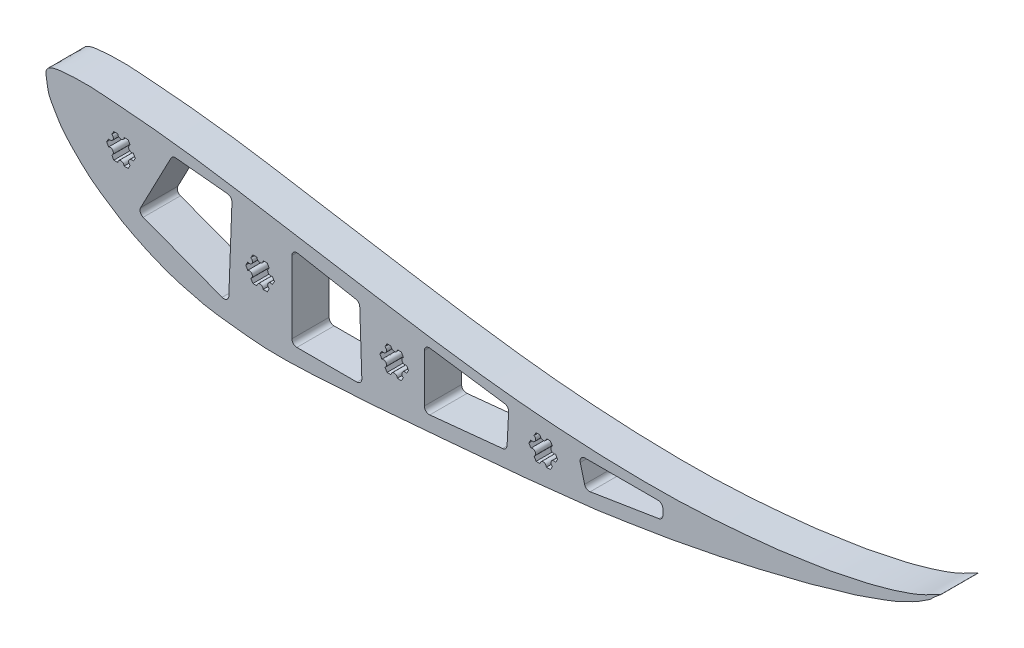
from build123d import *

# Parameters (mm, degrees)
BOSS_EXTRUDE1_DEPTH = 19.05
CUT_EXTRUDE3_DEPTH  = 381


with BuildPart() as part:
    # Sketch1 → Boss-Extrude1 (new body)
    with BuildSketch(Plane.XY):
        with BuildLine():
            add(Edge.make_bspline(
                [(-16.622525288, 91.56967272), (-16.794942994, 92.772317911), (-17.515788121, 97.582670832), (-2.852582554, 99.497127174), (9.154054709, 99.213304724), (23.433217875, 97.797752429), (34.6859051, 97.019819773), (46.592767258, 95.707761604), (58.472171701, 94.254609297), (72.666253463, 92.219697635), (88.15460255, 89.685431784), (109.15740223, 86.162485471), (130.076144789, 82.711728928), (150.055716296, 79.576696099), (168.256858053, 76.617688262), (186.559493812, 73.857794613), (206.695059336, 71.20791695), (225.195546149, 69.114961125), (244.068606399, 67.656695297), (262.594452449, 66.476567979), (282.222526995, 65.926744761), (300.99609332, 65.813021246), (318.737894065, 66.539084176), (334.742865336, 67.61277327), (348.252438633, 69.009944705), (359.067906447, 70.049570339), (367.896874578, 71.420704301), (377.007425502, 72.883057797), (386.227823421, 74.138373924), (395.367743176, 76.385575861), (403.564697097, 77.907582397), (410.735250399, 79.953005658), (417.114285798, 81.687412008), (422.732680223, 83.591992804), (427.164087313, 85.094079009), (431.171696898, 86.937153076), (434.607250511, 88.392786361), (443.123217376, 93.275688905), (437.255094337, 89.117703468), (435.279778464, 86.561175616), (431.573501891, 84.704524529), (428.464842726, 82.201032813), (424.134266462, 80.398696308), (419.425258521, 77.797857577), (414.105440345, 75.713007702), (408.77839072, 73.798734141), (403.684867312, 72.029145889), (396.961540144, 69.466067962), (387.343622202, 67.136732033), (376.830663922, 63.608926675), (365.24798357, 60.901656463), (354.754672426, 58.255886458), (344.650791699, 55.720154361), (336.670341174, 53.941801639), (329.235250959, 52.381752299), (321.327868225, 50.676833739), (310.892392252, 48.725728026), (298.426712372, 46.308387166), (284.136528131, 44.189578856), (268.909448728, 41.574011521), (251.075314715, 39.596728872), (229.386892765, 37.203012777), (203.753382466, 34.933554815), (177.46976253, 32.720447696), (150.443659112, 30.344574846), (123.02307167, 28.688327838), (101.004781565, 27.555963663), (84.804305156, 28.931500406), (75.72348416, 30.010523718), (67.270753352, 30.977463397), (60.250592801, 32.582425676), (53.932519662, 34.232006507), (47.114759922, 36.133551764), (41.43120503, 38.368275103), (36.428795002, 40.445297648), (32.069577899, 42.402430324), (27.662403595, 44.667790264), (23.104788958, 46.965799851), (18.73168781, 49.734821084), (12.723675127, 53.669846892), (5.809434759, 58.404883079), (-1.037305312, 65.077409289), (-6.513200759, 70.614178991), (-10.540658158, 76.008047875), (-12.880350205, 80.406543609), (-15.167480815, 84.128221175), (-16.123087236, 87.961419413), (-16.453570873, 90.391184614), (-16.622525288, 91.56967272)],
                knots=[0, 0, 0, 0, 0.003644297, 0.013581344, 0.034074787, 0.047557163, 0.057150579, 0.06958931, 0.084962672, 0.094623108, 0.114452008, 0.134073068, 0.161263036, 0.180794832, 0.197357561, 0.218965716, 0.238711125, 0.26090768, 0.277214827, 0.297940316, 0.318988728, 0.338651177, 0.356673355, 0.374539934, 0.388835783, 0.399172974, 0.408530924, 0.416784345, 0.428053881, 0.437617365, 0.446213781, 0.454125754, 0.460928052, 0.466918155, 0.472615005, 0.475771621, 0.480179638, 0.487250343, 0.490988881, 0.49507496, 0.498775568, 0.503369536, 0.507624299, 0.513322415, 0.520215853, 0.525455504, 0.531043662, 0.537088919, 0.5479516, 0.561953721, 0.571760074, 0.585151118, 0.595822817, 0.604354359, 0.61073386, 0.619595652, 0.629664863, 0.643953388, 0.659323518, 0.674864947, 0.692287919, 0.715453133, 0.743149301, 0.772805526, 0.797998576, 0.828023399, 0.858832685, 0.866768477, 0.87886578, 0.88746214, 0.893357873, 0.901377327, 0.907903322, 0.915486693, 0.920464298, 0.924856032, 0.930432876, 0.935970498, 0.940815755, 0.946613865, 0.958462559, 0.966932993, 0.97647901, 0.982815006, 0.98789669, 0.992067686, 0.996428904, 1, 1, 1, 1], degree=3))
        make_face()
    extrude(amount=BOSS_EXTRUDE1_DEPTH)

    # Sketch4 → Cut-Extrude3 (cut)
    with BuildSketch(Plane.XY.offset(19.05)):
        with BuildLine():
            Line((88.931300118, 66.243537573), (91.009974327, 66.243537573))
            ThreePointArc((91.009974327, 66.243537573), (92.597474327, 64.656037573), (94.184974327, 66.243537573))
            Line((94.184974327, 66.243537573), (96.263648536, 66.243537573))
            Line((96.263648536, 66.243537573), (97.302985641, 64.443352902))
            ThreePointArc((97.302985641, 64.443352902), (96.721920503, 62.274787243), (98.890486301, 61.693722626))
            Line((98.890486301, 61.693722626), (99.929823515, 59.893537766))
            Line((99.929823515, 59.893537766), (98.89048641, 58.093353094))
            ThreePointArc((98.89048641, 58.093353094), (96.721921082, 57.512287766), (97.30298641, 55.343722437))
            Line((97.30298641, 55.343722437), (96.263649306, 53.543537766))
            Line((96.263649306, 53.543537766), (94.184975096, 53.543537766))
            ThreePointArc((94.184975096, 53.543537766), (92.597475, 55.131037573), (91.009975096, 53.543537573))
            Line((91.009975096, 53.543537573), (88.931300887, 53.543537573))
            Line((88.931300887, 53.543537573), (87.891963673, 55.343722182))
            ThreePointArc((87.891963673, 55.343722182), (88.47302887, 57.512287545), (86.304463507, 58.093352743))
            Line((86.304463507, 58.093352743), (85.265126293, 59.893537351))
            Line((85.265126293, 59.893537351), (86.304463288, 61.693722086))
            ThreePointArc((86.304463288, 61.693722086), (88.473028582, 62.274787545), (87.891963122, 64.443352839))
            Line((87.891963122, 64.443352839), (88.931300118, 66.243537573))
        make_face()
        with BuildLine():
            Line((17.811300118, 85.293537573), (19.889974327, 85.293537573))
            ThreePointArc((19.889974327, 85.293537573), (21.477474327, 83.706037573), (23.064974327, 85.293537573))
            Line((23.064974327, 85.293537573), (25.143648536, 85.293537573))
            Line((25.143648536, 85.293537573), (26.182985641, 83.493352902))
            ThreePointArc((26.182985641, 83.493352902), (25.601920503, 81.324787243), (27.770486301, 80.743722626))
            Line((27.770486301, 80.743722626), (28.809823515, 78.943537766))
            Line((28.809823515, 78.943537766), (27.77048641, 77.143353094))
            ThreePointArc((27.77048641, 77.143353094), (25.601921082, 76.562287766), (26.18298641, 74.393722437))
            Line((26.18298641, 74.393722437), (25.143649306, 72.593537766))
            Line((25.143649306, 72.593537766), (23.064975096, 72.593537766))
            ThreePointArc((23.064975096, 72.593537766), (21.477475, 74.181037573), (19.889975096, 72.593537573))
            Line((19.889975096, 72.593537573), (17.811300887, 72.593537573))
            Line((17.811300887, 72.593537573), (16.771963673, 74.393722182))
            ThreePointArc((16.771963673, 74.393722182), (17.35302887, 76.562287545), (15.184463507, 77.143352743))
            Line((15.184463507, 77.143352743), (14.145126293, 78.943537351))
            Line((14.145126293, 78.943537351), (15.184463288, 80.743722086))
            ThreePointArc((15.184463288, 80.743722086), (17.353028582, 81.324787545), (16.771963122, 83.493352839))
            Line((16.771963122, 83.493352839), (17.811300118, 85.293537573))
        make_face()
        with BuildLine():
            Line((233.711300118, 59.893537573), (235.789974327, 59.893537573))
            ThreePointArc((235.789974327, 59.893537573), (237.377474327, 58.306037573), (238.964974327, 59.893537573))
            Line((238.964974327, 59.893537573), (241.043648536, 59.893537573))
            Line((241.043648536, 59.893537573), (242.082985641, 58.093352902))
            ThreePointArc((242.082985641, 58.093352902), (241.501920503, 55.924787243), (243.670486301, 55.343722626))
            Line((243.670486301, 55.343722626), (244.709823515, 53.543537766))
            Line((244.709823515, 53.543537766), (243.67048641, 51.743353094))
            ThreePointArc((243.67048641, 51.743353094), (241.501921082, 51.162287766), (242.08298641, 48.993722437))
            Line((242.08298641, 48.993722437), (241.043649306, 47.193537766))
            Line((241.043649306, 47.193537766), (238.964975096, 47.193537766))
            ThreePointArc((238.964975096, 47.193537766), (237.377475, 48.781037573), (235.789975096, 47.193537573))
            Line((235.789975096, 47.193537573), (233.711300887, 47.193537573))
            Line((233.711300887, 47.193537573), (232.671963673, 48.993722182))
            ThreePointArc((232.671963673, 48.993722182), (233.25302887, 51.162287545), (231.084463507, 51.743352743))
            Line((231.084463507, 51.743352743), (230.045126293, 53.543537351))
            Line((230.045126293, 53.543537351), (231.084463288, 55.343722086))
            ThreePointArc((231.084463288, 55.343722086), (233.253028582, 55.924787545), (232.671963122, 58.093352839))
            Line((232.671963122, 58.093352839), (233.711300118, 59.893537573))
        make_face()
        with BuildLine():
            Line((157.511300118, 61.163537573), (159.589974327, 61.163537573))
            ThreePointArc((159.589974327, 61.163537573), (161.177474327, 59.576037573), (162.764974327, 61.163537573))
            Line((162.764974327, 61.163537573), (164.843648536, 61.163537573))
            Line((164.843648536, 61.163537573), (165.882985641, 59.363352902))
            ThreePointArc((165.882985641, 59.363352902), (165.301920503, 57.194787243), (167.470486301, 56.613722626))
            Line((167.470486301, 56.613722626), (168.509823515, 54.813537766))
            Line((168.509823515, 54.813537766), (167.47048641, 53.013353094))
            ThreePointArc((167.47048641, 53.013353094), (165.301921082, 52.432287766), (165.88298641, 50.263722437))
            Line((165.88298641, 50.263722437), (164.843649306, 48.463537766))
            Line((164.843649306, 48.463537766), (162.764975096, 48.463537766))
            ThreePointArc((162.764975096, 48.463537766), (161.177475, 50.051037573), (159.589975096, 48.463537573))
            Line((159.589975096, 48.463537573), (157.511300887, 48.463537573))
            Line((157.511300887, 48.463537573), (156.471963673, 50.263722182))
            ThreePointArc((156.471963673, 50.263722182), (157.05302887, 52.432287545), (154.884463507, 53.013352743))
            Line((154.884463507, 53.013352743), (153.845126293, 54.813537351))
            Line((153.845126293, 54.813537351), (154.884463288, 56.613722086))
            ThreePointArc((154.884463288, 56.613722086), (157.053028582, 57.194787545), (156.471963122, 59.363352839))
            Line((156.471963122, 59.363352839), (157.511300118, 61.163537573))
        make_face()
        with BuildLine():
            Line((31.501207482, 58.37669779), (47.032113751, 88.081016492))
            ThreePointArc((47.032113751, 88.081016492), (48.076445172, 89.139261035), (49.534182489, 89.431684603))
            Line((49.534182489, 89.431684603), (75.93058222, 86.808602351))
            ThreePointArc((75.93058222, 86.808602351), (77.593752589, 85.950453195), (78.217633108, 84.185990458))
            Line((78.217633108, 84.185990458), (76.631821885, 41.843273018))
            ThreePointArc((76.631821885, 41.843273018), (75.497981954, 39.821894696), (73.194863199, 39.56265096))
            Line((73.194863199, 39.56265096), (32.853368422, 54.824131949))
            ThreePointArc((32.853368422, 54.824131949), (31.378241648, 56.296285615), (31.501207482, 58.37669779))
        make_face()
        with BuildLine():
            Line((111.858309541, 78.393902518), (141.485442222, 72.962296795))
            ThreePointArc((141.485442222, 72.962296795), (142.950940478, 72.12274223), (143.565962065, 70.549756072))
            Line((143.565962065, 70.549756072), (144.628770085, 39.112135773))
            ThreePointArc((144.628770085, 39.112135773), (143.916361615, 37.260866924), (142.090220332, 36.486315313))
            Line((142.090220332, 36.486315313), (111.400279631, 36.486315313))
            ThreePointArc((111.400279631, 36.486315313), (109.604228407, 37.230264089), (108.860279631, 39.026315313))
            Line((108.860279631, 39.026315313), (108.860279631, 75.895541334))
            ThreePointArc((108.860279631, 75.895541334), (109.774210132, 77.846822448), (111.858309541, 78.393902518))
        make_face()
        with BuildLine():
            Line((179.473393864, 70.165192722), (217.50482476, 64.769576264))
            ThreePointArc((217.50482476, 64.769576264), (219.108331349, 63.86995645), (219.68467301, 62.123995546))
            Line((219.68467301, 62.123995546), (218.890378913, 46.71578744))
            ThreePointArc((218.890378913, 46.71578744), (218.192789678, 45.094545708), (216.607247121, 44.319232678))
            Line((216.607247121, 44.319232678), (179.370110323, 40.58420072))
            ThreePointArc((179.370110323, 40.58420072), (177.412540188, 41.227973149), (176.576610312, 43.111519011))
            Line((176.576610312, 43.111519011), (176.576610312, 67.650375533))
            ThreePointArc((176.576610312, 67.650375533), (177.451472213, 69.568425352), (179.473393864, 70.165192722))
        make_face()
        with BuildLine():
            Line((258.751236774, 61.163537573), (296.003687002, 61.163537573))
            ThreePointArc((296.003687002, 61.163537573), (297.799738226, 60.419588797), (298.543687002, 58.623537573))
            Line((298.543687002, 58.623537573), (298.543687002, 55.707363059))
            ThreePointArc((298.543687002, 55.707363059), (297.937199117, 54.060204626), (296.407363457, 53.199645906))
            Line((296.407363457, 53.199645906), (261.377375447, 47.560739881))
            ThreePointArc((261.377375447, 47.560739881), (259.584877656, 47.941775277), (258.515299797, 49.429807368))
            Line((258.515299797, 49.429807368), (256.292837579, 57.984887907))
            ThreePointArc((256.292837579, 57.984887907), (256.742036666, 60.177472876), (258.751236774, 61.163537573))
        make_face()
    extrude(amount=-CUT_EXTRUDE3_DEPTH, mode=Mode.SUBTRACT)


solid = part.part
